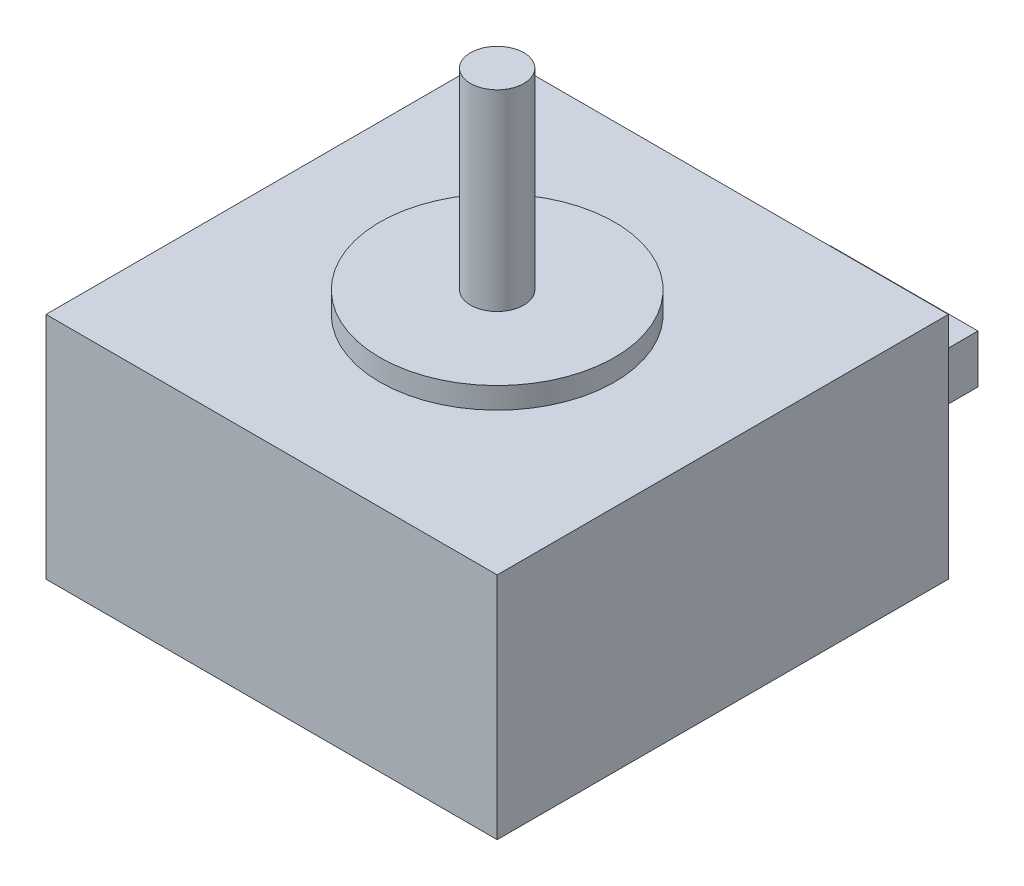
from build123d import *

# Parameters (mm, degrees)
SKETCH1_W           = 42.3
SKETCH1_H           = 42.3
BOSS_EXTRUDE1_DEPTH = 21.5
SKETCH2_R           = 11
BOSS_EXTRUDE2_DEPTH = 2
SKETCH3_R           = 2.5
BOSS_EXTRUDE3_DEPTH = 18
SKETCH4_W           = 13.852605362
SKETCH4_H           = 4.542451726
BOSS_EXTRUDE4_DEPTH = 17


with BuildPart() as part:
    # Sketch1 → Boss-Extrude1 (new body)
    with BuildSketch(Plane(origin=(0, 0, 0), x_dir=(1, 0, 0), z_dir=(0, 1, 0))):
        with Locations((-15.194404332, -5.802888087)):
            Rectangle(SKETCH1_W, SKETCH1_H)
    extrude(amount=BOSS_EXTRUDE1_DEPTH)

    # Sketch2 → Boss-Extrude2 (add)
    with BuildSketch(Plane(origin=(0, 21.5, 0), x_dir=(1, 0, 0), z_dir=(0, 1, 0))):
        with Locations((-15.194404332, -5.802888087)):
            Circle(SKETCH2_R)
    extrude(amount=BOSS_EXTRUDE2_DEPTH)

    # Sketch3 → Boss-Extrude3 (add)
    with BuildSketch(Plane(origin=(0, 23.5, 0), x_dir=(1, 0, 0), z_dir=(0, 1, 0))):
        with Locations((-15.194404332, -5.802888087)):
            Circle(SKETCH3_R)
    extrude(amount=BOSS_EXTRUDE3_DEPTH)

    # Sketch4 → Boss-Extrude4 (add)
    with BuildSketch(Plane(origin=(0, 0, -15.347111913), x_dir=(-1, 0, 0), z_dir=(0, 0, -1))):
        with Locations((15.194404332, 2.271225863)):
            Rectangle(SKETCH4_W, SKETCH4_H)
    extrude(amount=BOSS_EXTRUDE4_DEPTH)


solid = part.part
